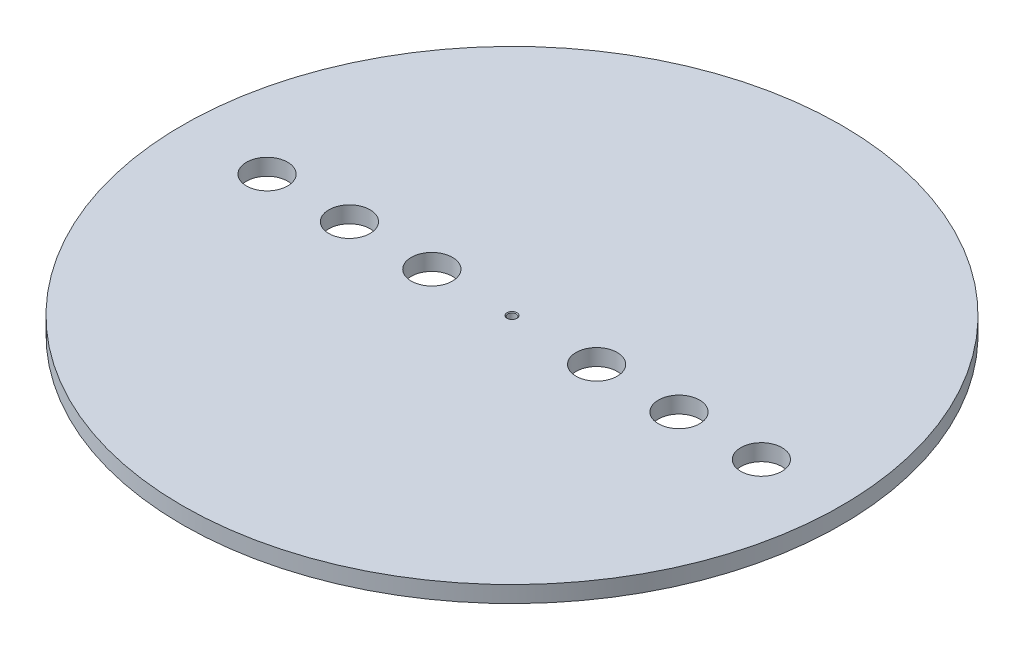
from build123d import *

# Parameters (mm, degrees)
SKETCH1_R                    = 400
BOSS_EXTRUDE1_DEPTH          = 20
SKETCH2_R                    = 25
CUT_EXTRUDE3_DEPTH           = 20
M12_TAPPED_HOLE1_D           = 10.2
M12_TAPPED_HOLE1_DEPTH       = 32.75
M12_TAPPED_HOLE1_CSINK_D     = 12.05
M12_TAPPED_HOLE1_CSINK_ANGLE = 90
M12_TAPPED_HOLE1_TIP         = 3.064389157


with BuildPart() as part:
    # Sketch1 → Boss-Extrude1 (new body)
    with BuildSketch(Plane(origin=(0, 0, 0), x_dir=(1, 0, 0), z_dir=(0, 1, 0))):
        Circle(SKETCH1_R)
    extrude(amount=BOSS_EXTRUDE1_DEPTH)

    # Sketch2 → Cut-Extrude3 (cut)
    with BuildSketch(Plane(origin=(0, 0, 0), x_dir=(1, 0, 0), z_dir=(0, 1, 0))):
        with Locations((102.698747746, 0)):
            Circle(SKETCH2_R)
        with Locations((202.698747746, 0)):
            Circle(SKETCH2_R)
        with Locations((302.698747746, 0)):
            Circle(SKETCH2_R)
        with Locations((-97.301252254, 0)):
            Circle(SKETCH2_R)
        with Locations((-197.301252254, 0)):
            Circle(SKETCH2_R)
        with Locations((-297.301252254, 0)):
            Circle(SKETCH2_R)
    extrude(amount=CUT_EXTRUDE3_DEPTH, mode=Mode.SUBTRACT)

    # M12 Tapped Hole1
    with Locations(Plane(origin=(0, 20, 0), x_dir=(1, 0, 0), z_dir=(0, 1, 0))):
        with Locations((0, 0)):
            CounterSinkHole(M12_TAPPED_HOLE1_D / 2, M12_TAPPED_HOLE1_CSINK_D / 2, depth=M12_TAPPED_HOLE1_DEPTH, counter_sink_angle=M12_TAPPED_HOLE1_CSINK_ANGLE)
            with Locations((0, 0, -(M12_TAPPED_HOLE1_DEPTH + M12_TAPPED_HOLE1_TIP / 2))):  # 118° drill point
                Cone(0, M12_TAPPED_HOLE1_D / 2, M12_TAPPED_HOLE1_TIP, mode=Mode.SUBTRACT)


solid = part.part
